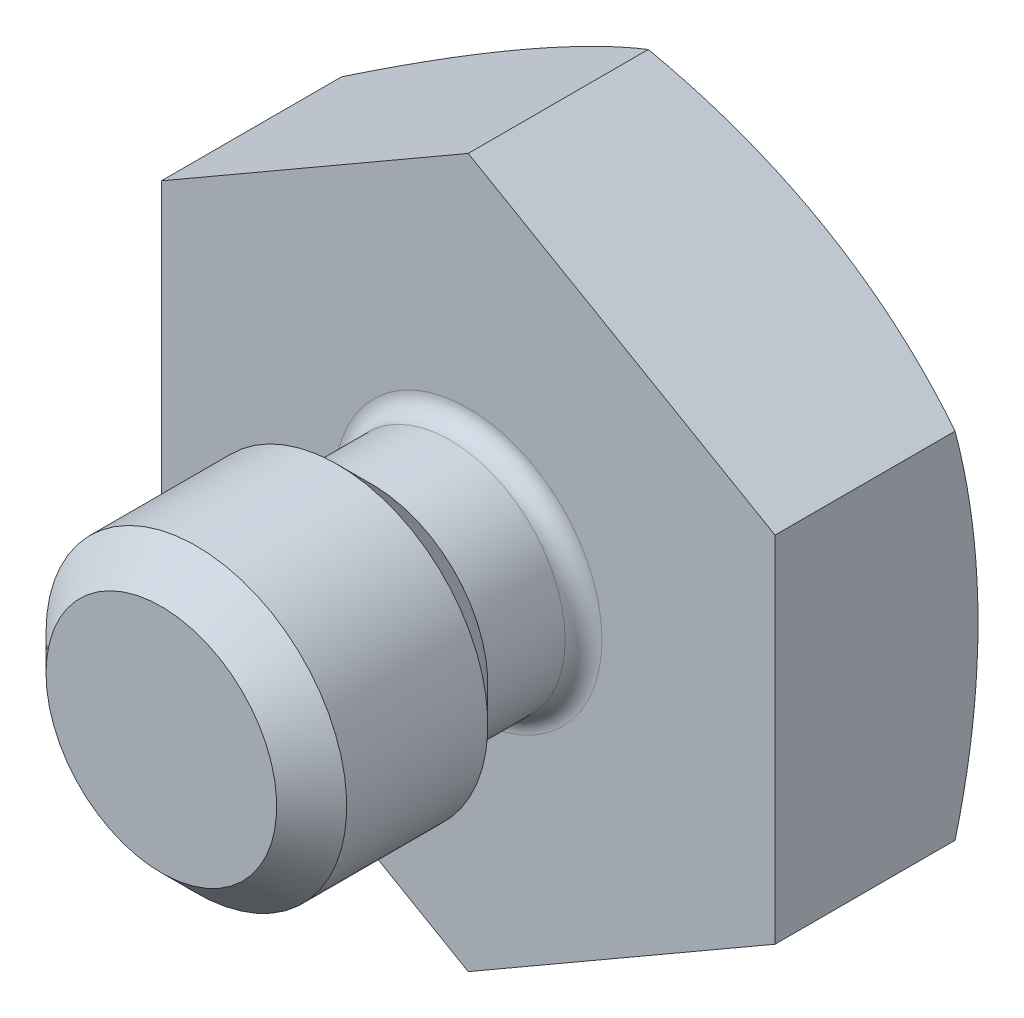
from build123d import *

# Parameters (mm, degrees)
SKETCH2_OUTSIDE_W  = 33.164
SKETCH2_OUTSIDE_H  = 33.164
CUT_EXTRUDE1_DEPTH = 6.5372
FILLET1_R          = 0.381


with BuildPart() as part:
    # Sketch1 → Revolve1 (revolve)
    with BuildSketch(Plane(origin=(0, 0, 0), x_dir=(0, 0, -1), z_dir=(1, 0, 0)), mode=Mode.PRIVATE) as revolve1_sk:
        with BuildLine():
            Line((0, 11.989122877), (0, 2.3876))
            Line((0, 2.3876), (-1.9812, 2.3876))
            Line((-1.9812, 2.3876), (-2.7051, 3.1115))
            Line((-2.7051, 3.1115), (-5.6261, 3.1115))
            Line((-5.6261, 3.1115), (-6.35, 2.3876))
            Line((-6.35, 2.3876), (-6.35, 0))
            Line((-6.35, 0), (5.5372, 0))
            ThreePointArc((5.5372, 0), (4.086038504, 6.603023005), (0, 11.989122877))
        make_face()
    revolve(revolve1_sk.sketch.rotate(Axis((0, 0, 0), (0, 0, 1)), 90), axis=Axis((0, 0, 0), (0, 0, 1)))  # turned: the seam where the file's is

    # Sketch2 outside → Cut-Extrude1 (cut, through all)
    with BuildSketch(Plane.XY):
        Rectangle(SKETCH2_OUTSIDE_W, SKETCH2_OUTSIDE_H)
        Polygon((0, 7.332348419), (-6.35, 3.666174209), (-6.35, -3.666174209), (0, -7.332348419), (6.35, -3.666174209), (6.35, 3.666174209), align=None, mode=Mode.SUBTRACT)
    extrude(amount=-CUT_EXTRUDE1_DEPTH, mode=Mode.SUBTRACT)

    # Fillet1
    fillet1_edges = [part.edges().sort_by_distance(p)[0] for p in [
        (2.3876, 0, 0),
    ]]
    fillet(fillet1_edges, radius=FILLET1_R)


solid = part.part
